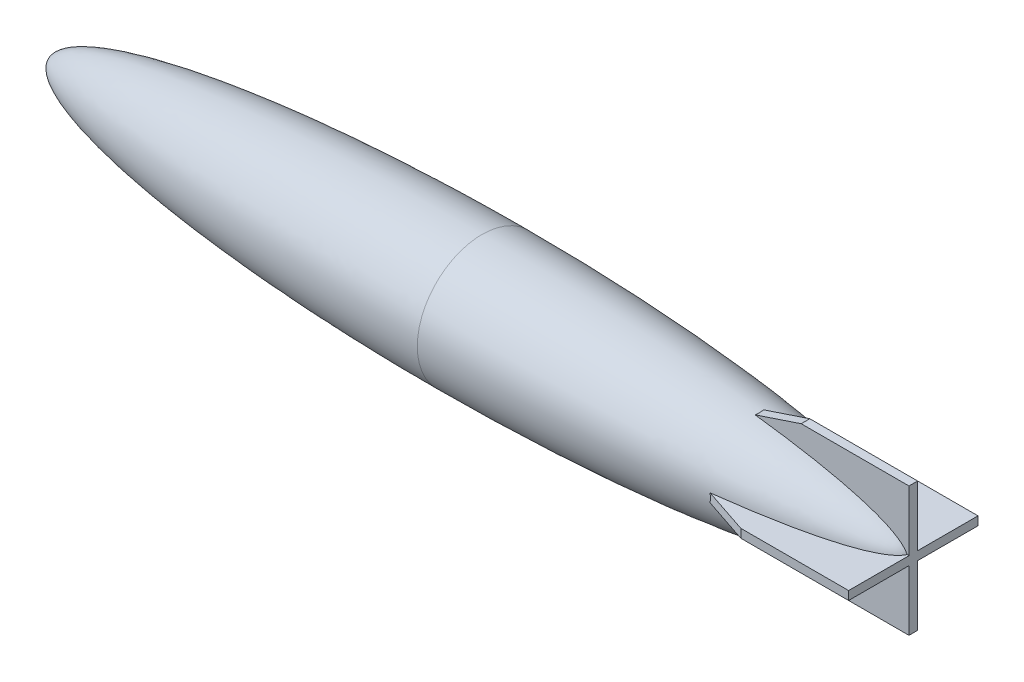
from build123d import *

# Parameters (mm, degrees)
BOSS_EXTRUDE2_DEPTH = 0.635
CIRPATTERN1_COUNT   = 2
CIRPATTERN1_ANGLE   = 90


with BuildPart() as part:
    # Sketch1 → Revolve1 (revolve)
    with BuildSketch(Plane.XY):
        with BuildLine():
            Line((0, 0), (63.5, 0))
            Line((63.5, 0), (63.5, 9.525))
            add(Edge.make_bspline(
                [(0, 0), (2.1884e-05, 0.061358281), (0.005701914, 0.160875035), (0.027121124, 0.302561176), (0.079051059, 0.486919815), (0.148177315, 0.660693353), (0.249784357, 0.854061157), (0.39582745, 1.072326528), (0.607448448, 1.326027818), (0.918307158, 1.62782122), (1.385855067, 1.996483344), (2.117482387, 2.462597205), (3.283322052, 3.05498177), (5.147059537, 3.798851001), (8.032393565, 4.68916887), (11.833678735, 5.585531046), (16.349849317, 6.418626383), (21.277100339, 7.142485475), (26.21954484, 7.733272073), (31.176907263, 8.217368394), (36.136297117, 8.611855069), (40.489965342, 8.888369768), (44.209287831, 9.081223476), (47.33355924, 9.214122835), (49.791560572, 9.304329595), (52.335110532, 9.378854571), (54.728096068, 9.438069047), (57.377606626, 9.482242766), (59.597261841, 9.511582932), (61.803368258, 9.522560513), (62.932688434, 9.525), (63.5, 9.525)],
                knots=[0, 0, 0, 0, 0, 0.003408116, 0.00554995, 0.007950478, 0.010643768, 0.013800696, 0.017688197, 0.02254339, 0.029002799, 0.037877158, 0.050780373, 0.070759325, 0.101702316, 0.14945249, 0.218740513, 0.288028523, 0.357316533, 0.42660455, 0.495892565, 0.56518058, 0.634468596, 0.669112603, 0.703756611, 0.738400619, 0.773044627, 0.807688634, 0.842332642, 0.87697665, 0.911620658, 0.911620658, 0.911620658, 0.911620658, 0.911620658], degree=4))
        make_face()
    revolve1 = revolve(axis=Axis((0, 0, 0), (1, 0, 0)))

    # Mirror1: Revolve1 across plane
    add(revolve1.mirror(Plane(origin=(63.5, 0, 0), x_dir=(0, 0, 1), z_dir=(1, 0, 0))))

    # Sketch3 → Boss-Extrude2 (add, symmetric)
    with BuildSketch(Plane.XY):
        Polygon((127, 9.525), (111.125, 9.525), (82.55, 0), (111.125, -9.525), (127, -9.525), align=None)
    boss_extrude2 = extrude(amount=BOSS_EXTRUDE2_DEPTH, both=True)

    # CirPattern1: Boss-Extrude2 ×2 about axis
    cirpattern1_axis = Axis((0, 0, 0), (-1, 0, 0))
    for i in range(1, CIRPATTERN1_COUNT):
        add(boss_extrude2.rotate(cirpattern1_axis, i * CIRPATTERN1_ANGLE / (CIRPATTERN1_COUNT - 1)))


solid = part.part
